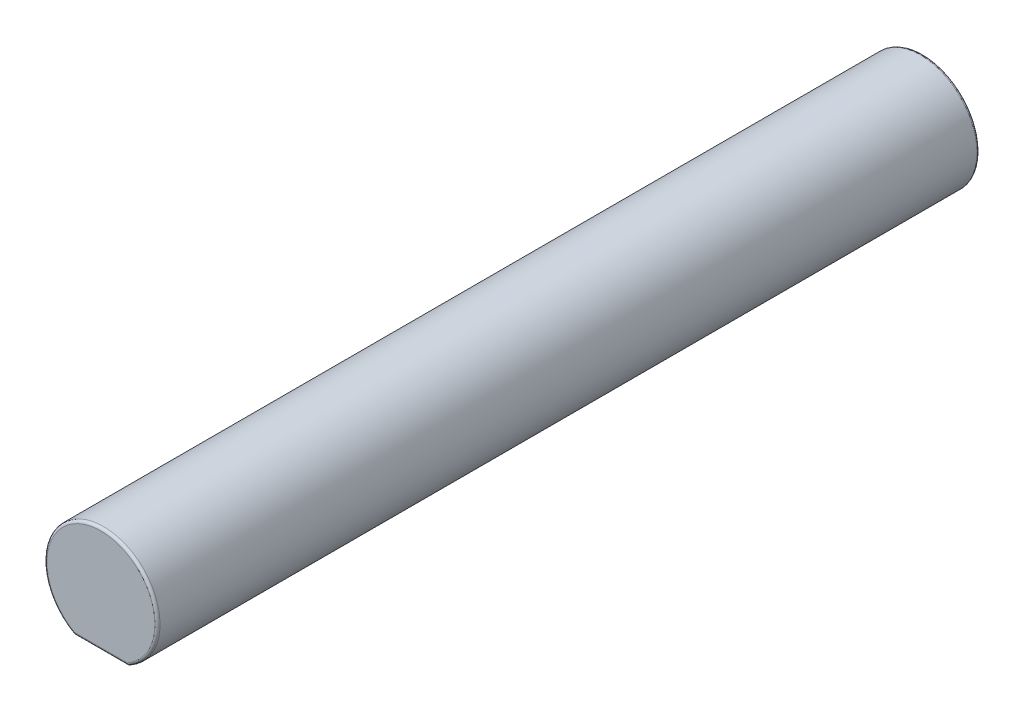
from build123d import *

# Parameters (mm, degrees)
SKETCH_1_R               = 22
EXTRUDE_1_DEPTH          = 320
SKETCH_3_W               = 21
SKETCH_3_H               = 42
CUT_EXTRUDE_1_DEPTH      = 40
CUT_EXTRUDE_2_DEPTH      = 130
CUT_EXTRUDE_2_DEPTH_BACK = 150
SKETCH_8_W               = 21
SKETCH_8_H               = 8
CUT_EXTRUDE_5_DEPTH      = 9.2
SKETCH_9_W               = 9.811196784
SKETCH_9_H               = 111
CUT_EXTRUDE_6_DEPTH      = 37.332615
FILLET_1_R               = 1
FILLET_2_R               = 1


with BuildPart() as part:
    # Sketch 1 → Extrude 1 (new body)
    with BuildSketch(Plane.XY):
        Circle(SKETCH_1_R)
    extrude(amount=EXTRUDE_1_DEPTH)

    # Sketch 3 → Cut-Extrude 1 (cut)
    with BuildSketch(Plane(origin=(0, -22, 0), x_dir=(-1, 0, 0), z_dir=(0, -1, 0))):
        with Locations((0, -150)):
            Rectangle(SKETCH_3_W, SKETCH_3_H)
    extrude(amount=-CUT_EXTRUDE_1_DEPTH, mode=Mode.SUBTRACT)

    # Sketch 5 → Cut-Extrude 2 (cut, two sides)
    with BuildSketch(Plane(origin=(0, 0, 171), x_dir=(-1, 0, 0), z_dir=(0, 0, -1))) as cut_extrude_2_sk:
        with BuildLine():
            Line((10.5, -19.332614929), (-10.5, -19.332614929))
            ThreePointArc((-10.5, -19.332614929), (0, -22), (10.5, -19.332614929))
        make_face()
    extrude(amount=CUT_EXTRUDE_2_DEPTH, mode=Mode.SUBTRACT)
    extrude(cut_extrude_2_sk.sketch, amount=-CUT_EXTRUDE_2_DEPTH_BACK, mode=Mode.SUBTRACT)

    # Sketch 8 → Cut-Extrude 5 (cut)
    with BuildSketch(Plane(origin=(0, -19.332614929, 0), x_dir=(-1, 0, 0), z_dir=(0, -1, 0))):
        with Locations((0, -175)):
            Rectangle(SKETCH_8_W, SKETCH_8_H)
        with Locations((0, -125)):
            Rectangle(SKETCH_8_W, SKETCH_8_H)
    extrude(amount=-CUT_EXTRUDE_5_DEPTH, mode=Mode.SUBTRACT)

    # Sketch 9 → Cut-Extrude 6 (cut)
    with BuildSketch(Plane(origin=(0, -19.332614929, 0), x_dir=(-1, 0, 0), z_dir=(0, -1, 0))):
        with Locations((0, -226.5)):
            Rectangle(SKETCH_9_W, SKETCH_9_H)
    extrude(amount=-CUT_EXTRUDE_6_DEPTH, mode=Mode.SUBTRACT)

    # Fillet 1
    fillet_1_edges = [part.edges().sort_by_distance(p)[0] for p in [
        (-22, 0, 0),
    ]]
    fillet(fillet_1_edges, radius=FILLET_1_R)

    # Fillet 2
    fillet_2_edges = [part.edges().sort_by_distance(p)[0] for p in [
        (-11.247221879, 18.907670401, 320),
        (0, -19.332614929, 320),
    ]]
    fillet(fillet_2_edges, radius=FILLET_2_R)


solid = part.part
